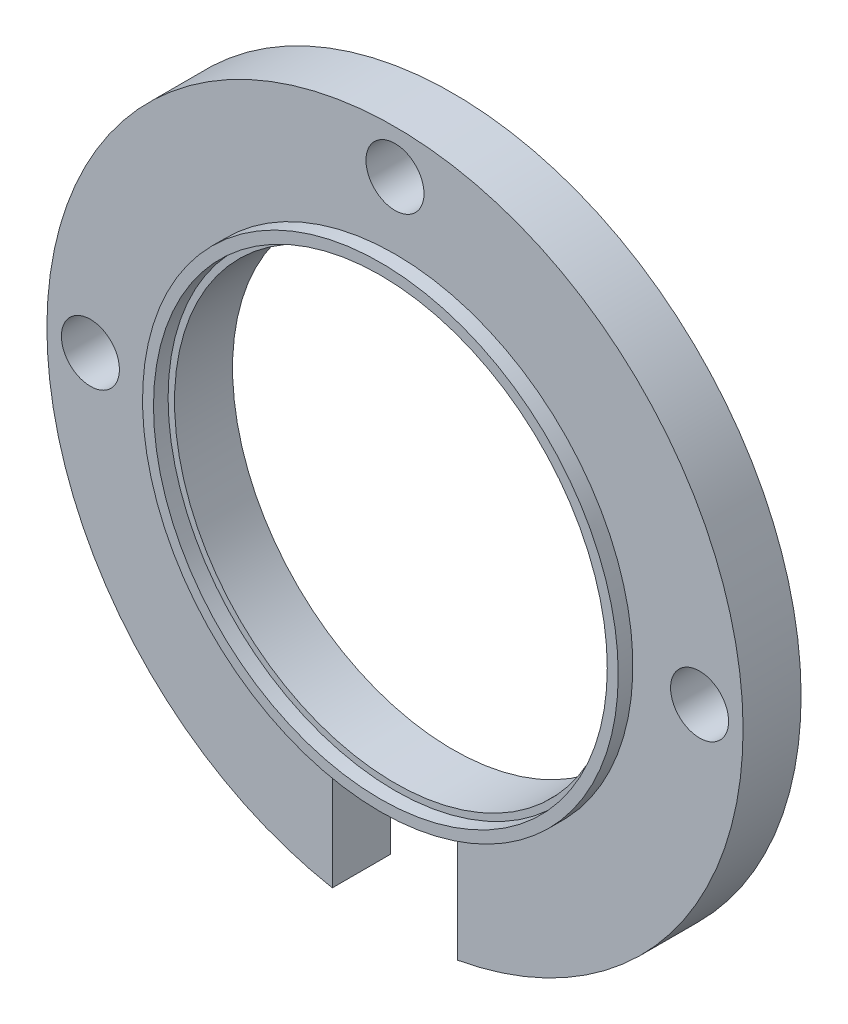
from build123d import *

# Parameters (mm, degrees)
SKETCH1_R           = 19.05
BOSS_EXTRUDE1_DEPTH = 3.175
SKETCH2_R           = 12.065
CUT_EXTRUDE1_DEPTH  = 4.175
SKETCH3_R           = 13.0175
SKETCH3_R_2         = 12.4175
BOSS_EXTRUDE2_DEPTH = 0.799999924
SKETCH4_W           = 6.858
SKETCH4_H           = 12.065
CUT_EXTRUDE2_DEPTH  = 4.175
SKETCH5_R           = 1.5875
CUT_EXTRUDE3_DEPTH  = 4.974999924


with BuildPart() as part:
    # Sketch1 → Boss-Extrude1 (new body)
    with BuildSketch(Plane.XY):
        Circle(SKETCH1_R)
    extrude(amount=BOSS_EXTRUDE1_DEPTH)

    # Sketch2 → Cut-Extrude1 (cut, through all)
    with BuildSketch(Plane.XY.offset(3.175)):
        Circle(SKETCH2_R)
    extrude(amount=-CUT_EXTRUDE1_DEPTH, mode=Mode.SUBTRACT)

    # Sketch3 → Boss-Extrude2 (add)
    with BuildSketch(Plane.XY.offset(3.175)):
        Circle(SKETCH3_R)
        Circle(SKETCH3_R_2, mode=Mode.SUBTRACT)
    extrude(amount=BOSS_EXTRUDE2_DEPTH)

    # Sketch4 → Cut-Extrude2 (cut, through all)
    with BuildSketch(Plane.XY.offset(3.175)):
        with Locations((0, -19.05)):
            Rectangle(SKETCH4_W, SKETCH4_H)
    extrude(amount=-CUT_EXTRUDE2_DEPTH, mode=Mode.SUBTRACT)

    # Sketch5 → Cut-Extrude3 (cut, through all)
    with BuildSketch(Plane(origin=(0, 0, 0), x_dir=(-1, 0, 0), z_dir=(0, 0, -1))):
        with Locations((-16.66875, 0)):
            Circle(SKETCH5_R)
        with Locations((0, 16.66875)):
            Circle(SKETCH5_R)
        with Locations((16.66875, 0)):
            Circle(SKETCH5_R)
    extrude(amount=-CUT_EXTRUDE3_DEPTH, mode=Mode.SUBTRACT)


solid = part.part
